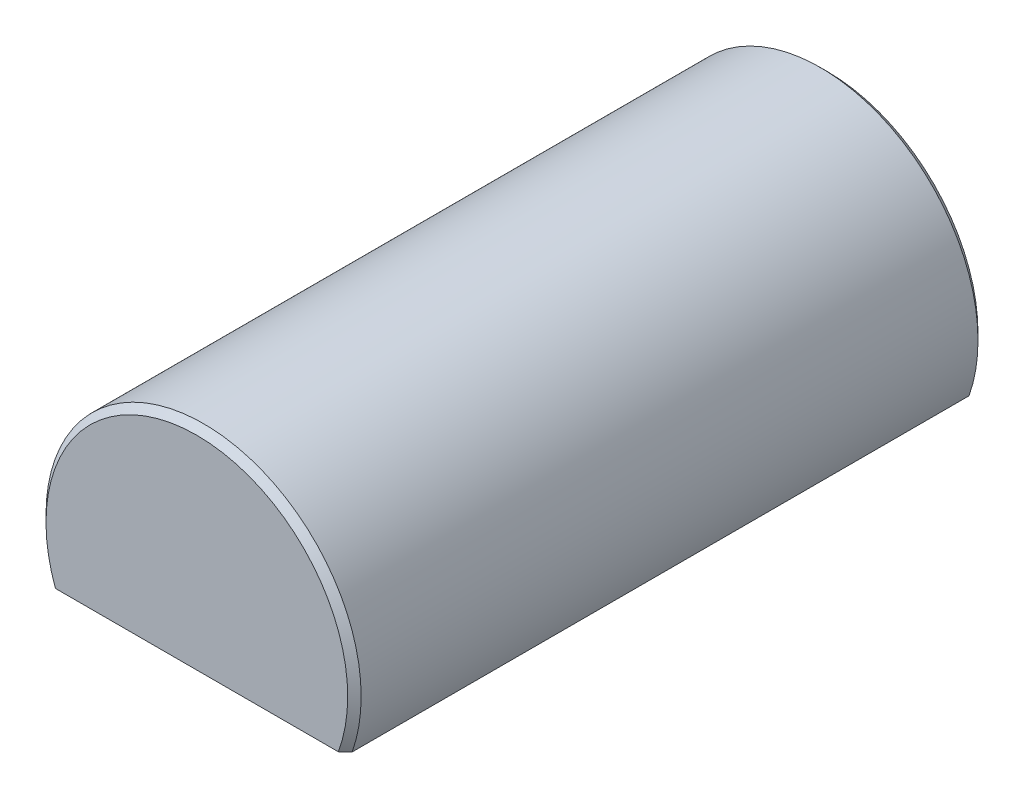
from build123d import *

# Parameters (mm, degrees)
SKETCH1_R            = 9.525
EXTRUDE1_DEPTH       = 19.05
CHAMFER1_SIZE        = 0.4064
TRUNCATED_DEPTH      = 20.05
TRUNCATED_DEPTH_BACK = 20.05


with BuildPart() as part:
    # Sketch1 → Extrude1 (new body, symmetric)
    with BuildSketch(Plane.XY):
        Circle(SKETCH1_R)
    extrude(amount=EXTRUDE1_DEPTH, both=True)

    # Chamfer1
    chamfer1_edges = [part.edges().sort_by_distance(p)[0] for p in [
        (-9.525, 0, -19.05),
        (-9.525, 0, 19.05),
    ]]
    chamfer(chamfer1_edges, length=CHAMFER1_SIZE)

    # Sketch2 → Truncated (cut, two sides)
    with BuildSketch(Plane.XY) as truncated_sk:
        with BuildLine():
            Line((-8.980256121, -3.175), (8.980256121, -3.175))
            ThreePointArc((8.980256121, -3.175), (0, -9.525), (-8.980256121, -3.175))
        make_face()
    extrude(amount=TRUNCATED_DEPTH, mode=Mode.SUBTRACT)
    extrude(truncated_sk.sketch, amount=-TRUNCATED_DEPTH_BACK, mode=Mode.SUBTRACT)


solid = part.part
